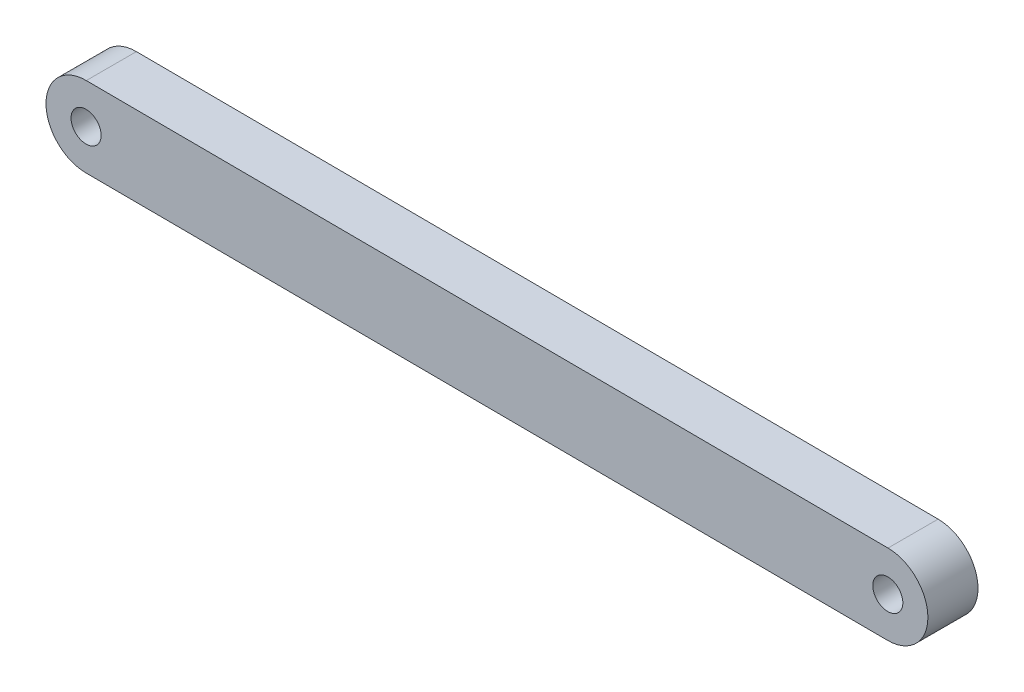
from build123d import *

# Parameters (mm, degrees)
SKETCH1_R           = 1.5
BOSS_EXTRUDE1_DEPTH = 5


with BuildPart() as part:
    # Sketch1 → Boss-Extrude1 (new body)
    with BuildSketch(Plane.XY):
        with BuildLine():
            Line((0.02000253, 3.999949987), (80.02000253, 3.599894394))
            ThreePointArc((80.02000253, 3.599894394), (83.999949987, -0.420058122), (79.97999747, -4.40000558))
            Line((79.97999747, -4.40000558), (-0.02000253, -3.999949987))
            ThreePointArc((-0.02000253, -3.999949987), (-3.999949987, 0.02000253), (0.02000253, 3.999949987))
        make_face()
        Circle(SKETCH1_R, mode=Mode.SUBTRACT)
        with Locations((80, -0.400055593)):
            Circle(SKETCH1_R, mode=Mode.SUBTRACT)
    extrude(amount=BOSS_EXTRUDE1_DEPTH)


solid = part.part
